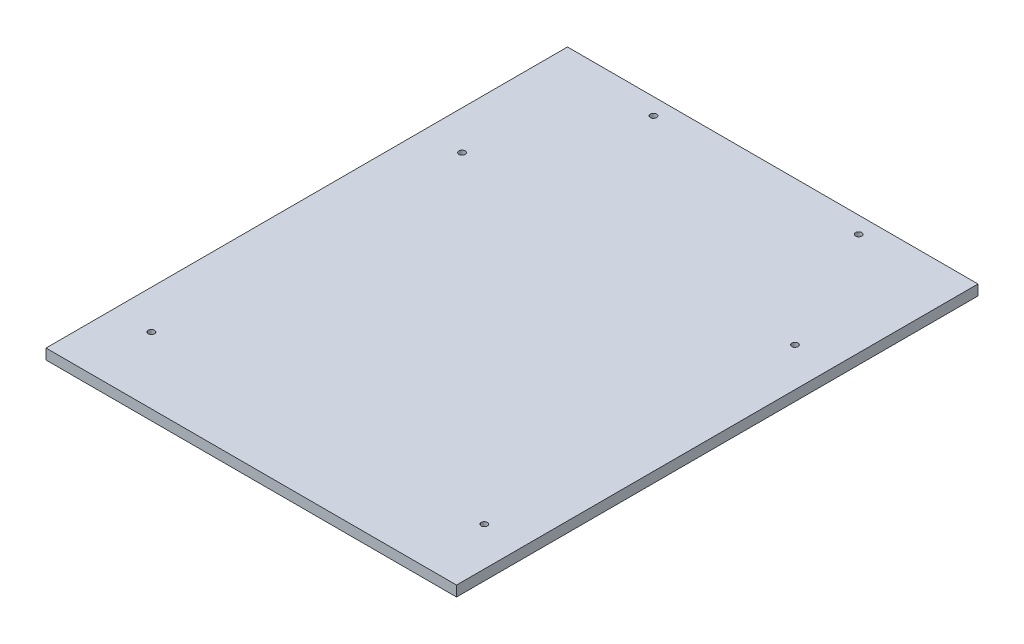
from build123d import *

# Parameters (mm, degrees)
SKETCH1_W                       = 469.9
SKETCH1_H                       = 596.9
BOSS_EXTRUDE1_DEPTH             = 11.90625
F_9_32_0_28125_DIAMETER_HOLE1_D = 7.14375


with BuildPart() as part:
    # Sketch1 → Boss-Extrude1 (new body)
    with BuildSketch(Plane(origin=(0, 0, 0), x_dir=(1, 0, 0), z_dir=(0, 1, 0))):
        Rectangle(SKETCH1_W, SKETCH1_H)
    extrude(amount=BOSS_EXTRUDE1_DEPTH)

    # 9/32 (0.28125) Diameter Hole1 (through all)
    with Locations(Plane(origin=(0, 11.90625, 0), x_dir=(1, 0, 0), z_dir=(0, 1, 0))):
        with Locations((-190.5, 133.35), (190.5, 133.35), (190.5, -222.25), (-190.5, -222.25), (-117.475, 279.4), (117.475, 279.4)):
            Hole(F_9_32_0_28125_DIAMETER_HOLE1_D / 2)


solid = part.part
